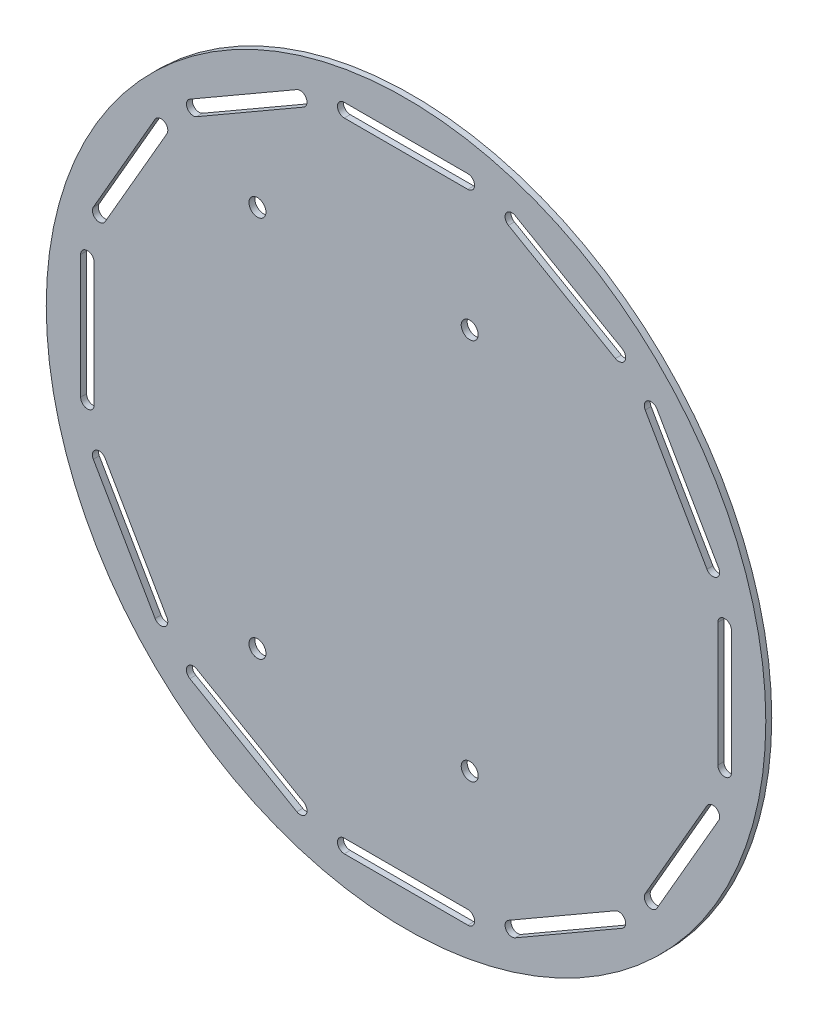
from build123d import *

# Parameters (mm, degrees)
SKETCH_1_R               = 84.75
SKETCH_1_R_2             = 2
EXTRUDE_1_DEPTH          = 1.4
CUT_EXTRUDE_1_DEPTH      = 1.4
PATTERN_CIRCULAR_1_COUNT = 12


with BuildPart() as part:
    # Эскиз1 → Бобышка-Вытянуть1 (new body)
    with BuildSketch(Plane.XY):
        Circle(SKETCH_1_R)
        with Locations((15, 45)):
            Circle(SKETCH_1_R_2, mode=Mode.SUBTRACT)
        with Locations((-35, 45)):
            Circle(SKETCH_1_R_2, mode=Mode.SUBTRACT)
        with Locations((-35, -45)):
            Circle(SKETCH_1_R_2, mode=Mode.SUBTRACT)
        with Locations((15, -45)):
            Circle(SKETCH_1_R_2, mode=Mode.SUBTRACT)
    extrude(amount=EXTRUDE_1_DEPTH)

    # Эскиз2 → Вырез-Вытянуть1 (cut)
    with BuildSketch(Plane.XY.offset(1.4)):
        with BuildLine():
            Line((73.45, -14.55), (73.45, 14.55))
            ThreePointArc((73.45, 14.55), (75.05, 16.15), (76.65, 14.55))
            Line((76.65, 14.55), (76.65, -14.55))
            ThreePointArc((76.65, -14.55), (75.05, -16.15), (73.45, -14.55))
        make_face()
    cut_extrude_1 = extrude(amount=-CUT_EXTRUDE_1_DEPTH, mode=Mode.SUBTRACT)

    # Круговой массив1: Вырез-Вытянуть1 ×12 about axis
    pattern_circular_1_axis = Axis((0, 0, 0), (0, 0, 1))
    for i in range(1, PATTERN_CIRCULAR_1_COUNT):
        add(cut_extrude_1.rotate(pattern_circular_1_axis, i * 360 / PATTERN_CIRCULAR_1_COUNT), mode=Mode.SUBTRACT)


solid = part.part
